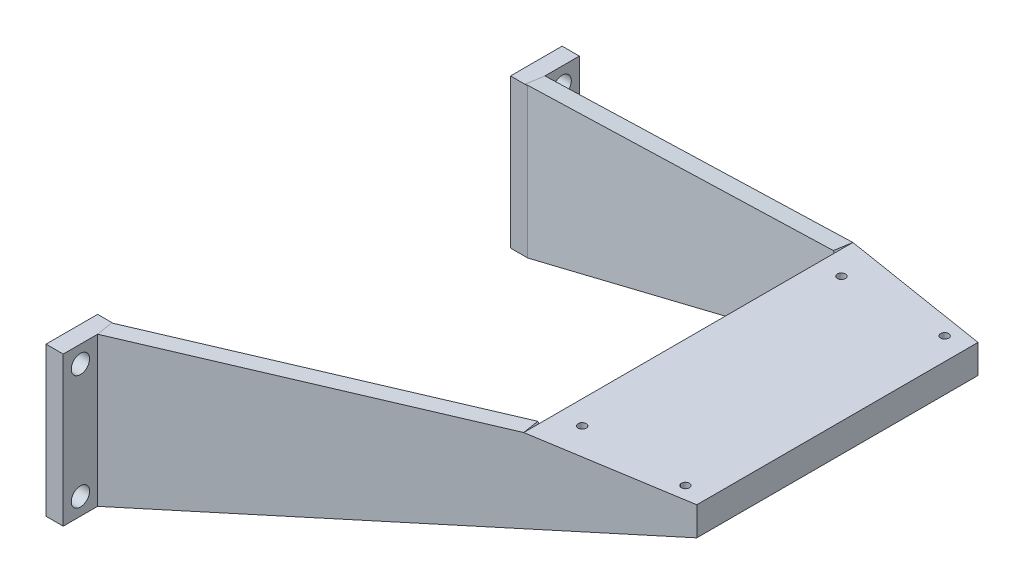
from build123d import *

# Parameters (mm, degrees)
SKETCH_1_W          = 6
SKETCH_1_H          = 26
SKETCH_1_R          = 1.6
EXTRUDE_1_DEPTH     = 3
EXTRUDE_1_2_DEPTH   = 3
SKETCH_11_W         = 3
SKETCH_11_H         = 10
SKETCH_10_W         = 3
SKETCH_10_H         = 26
SKETCH_13_W         = 3
SKETCH_13_H         = 10
SKETCH_12_W         = 3
SKETCH_12_H         = 26
SKETCH_14_W         = 50
SKETCH_14_H         = 10
EXTRUDE_4_DEPTH     = 3
SKETCH_15_W         = 19.024799208
SKETCH_15_H         = 22.305451654
CUT_EXTRUDE_2_DEPTH = 3
SKETCH_16_W         = 14.351226191
SKETCH_16_H         = 17.437681629
CUT_EXTRUDE_3_DEPTH = 3
SKETCH_17_W         = 3
SKETCH_17_H         = 26
EXTRUDE_5_DEPTH     = 3
EXTRUDE_6_DEPTH     = 3
EXTRUDE_10_DEPTH    = 2.961896
EXTRUDE_11_DEPTH    = 2.961896
CUT_EXTRUDE_4_DEPTH = 100
SKETCH_22_W         = 3
SKETCH_22_H         = 51.402298851
EXTRUDE_12_DEPTH    = 3
CUT_EXTRUDE_5_DEPTH = 3
SKETCH_24_R         = 0.7
CUT_EXTRUDE_6_DEPTH = 10


with BuildPart() as part:
    # 草图1 → 凸台-拉伸1 (new body)
    with BuildSketch(Plane(origin=(0, 0, 0), x_dir=(0, 0, -1), z_dir=(1, 0, 0))):
        with Locations((-2.817174515, -6.083780501)):
            Rectangle(SKETCH_1_W, SKETCH_1_H)
        with Locations((-2.817174515, -16.083780501)):
            Circle(SKETCH_1_R, mode=Mode.SUBTRACT)
        with Locations((-2.817174515, 3.916219499)):
            Circle(SKETCH_1_R, mode=Mode.SUBTRACT)
    extrude(amount=EXTRUDE_1_DEPTH)



with BuildPart() as body_2:
    # 草图1 → Extrude 1 2 (new body)
    with BuildSketch(Plane(origin=(0, 0, 0), x_dir=(0, 0, -1), z_dir=(1, 0, 0))):
        with Locations((-86.817174515, -6.083780501)):
            Rectangle(SKETCH_1_W, SKETCH_1_H)
        with Locations((-86.817174515, -16.083780501)):
            Circle(SKETCH_1_R, mode=Mode.SUBTRACT)
        with Locations((-86.817174515, 3.916219499)):
            Circle(SKETCH_1_R, mode=Mode.SUBTRACT)
    extrude(amount=EXTRUDE_1_2_DEPTH)


with BuildPart() as body_3:
    # 草图11 → 放样4 section 0
    with BuildSketch(Plane.ZY.offset(-90)):
        with Locations((21.317174515, 13.916219499)):
            Rectangle(SKETCH_11_W, SKETCH_11_H)
    # 草图10 → 放样4 section 1
    with BuildSketch(Plane(origin=(3, 0, 0), x_dir=(0, 0, -1), z_dir=(1, 0, 0))):
        with Locations((-7.317174515, -6.083780501)):
            Rectangle(SKETCH_10_W, SKETCH_10_H)
    loft()



with BuildPart() as body_4:
    # 草图13 → 放样5 section 0
    with BuildSketch(Plane.ZY.offset(-90)):
        with Locations((68.317174515, 13.916219499)):
            Rectangle(SKETCH_13_W, SKETCH_13_H)
    # 草图12 → 放样5 section 1
    with BuildSketch(Plane(origin=(3, 0, 0), x_dir=(0, 0, -1), z_dir=(1, 0, 0))):
        with Locations((-82.317174515, -6.083780501)):
            Rectangle(SKETCH_12_W, SKETCH_12_H)
    loft()


with BuildPart() as body_3_1:
    add(body_3.part)

    add(body_4.part)  # 凸台-拉伸4 merges body 4
    # 草图14 → 凸台-拉伸4 (add)
    with BuildSketch(Plane(origin=(90, 0, 0), x_dir=(0, 0, -1), z_dir=(1, 0, 0))):
        with Locations((-44.817174515, 13.916219499)):
            Rectangle(SKETCH_14_W, SKETCH_14_H)
    extrude(amount=EXTRUDE_4_DEPTH)

    # 草图15 → 切除-拉伸2 (cut)
    with BuildSketch(Plane(origin=(13.223093182, 0, 82.172079061), x_dir=(0.987298603, 0, -0.158875637), z_dir=(0.158875637, 0, 0.987298603))):
        with Locations((78.439469875, 13.430311671)):
            Rectangle(SKETCH_15_W, SKETCH_15_H)
    extrude(amount=CUT_EXTRUDE_2_DEPTH, mode=Mode.SUBTRACT)

    # 草图16 → 切除-拉伸3 (cut)
    with BuildSketch(Plane(origin=(-0.83674418, 0, 5.199767406), x_dir=(-0.987298603, 0, -0.158875637), z_dir=(0.158875637, 0, -0.987298603))):
        with Locations((-93.553254701, 14.072952005)):
            Rectangle(SKETCH_16_W, SKETCH_16_H)
    extrude(amount=CUT_EXTRUDE_3_DEPTH, mode=Mode.SUBTRACT)


with BuildPart() as part_1:
    add(part.part)

    add(body_2.part)  # 凸台-拉伸5 merges body 2

    add(body_3_1.part)  # 凸台-拉伸5 merges body 3
    # 草图17 → 凸台-拉伸5 (add)
    with BuildSketch(Plane.ZY.offset(-3)):
        with Locations((7.317174515, -6.083780501)):
            Rectangle(SKETCH_17_W, SKETCH_17_H)
        with Locations((82.317174515, -6.083780501)):
            Rectangle(SKETCH_17_W, SKETCH_17_H)
    extrude(amount=EXTRUDE_5_DEPTH)

    # 草图18 → 凸台-拉伸6 (add)
    with BuildSketch(Plane(origin=(0, 18.916219499, 0), x_dir=(1, 0, 0), z_dir=(0, 1, 0))):
        Polygon((93, -69.334415895), (67, -73.518323941), (67, -16.11602509), (93, -20.299933136), align=None)
    extrude(amount=-EXTRUDE_6_DEPTH)

    # 草图19 → 凸台-拉伸10 (add)
    with BuildSketch(Plane(origin=(13.223093182, 0, 82.172079061), x_dir=(0.987298603, 0, -0.158875637), z_dir=(0.158875637, 0, 0.987298603))):
        Polygon((-10.354611208, 6.916219499), (54.468735845, 18.916219499), (57.643062592, 15.200587801), (10.872988387, 4.084352126), align=None)
    extrude(amount=-EXTRUDE_10_DEPTH)

    # 草图20 → 凸台-拉伸11 (add)
    with BuildSketch(Plane(origin=(-0.83674418, 0, 5.199767406), x_dir=(-0.987298603, 0, -0.158875637), z_dir=(0.158875637, 0, -0.987298603))):
        Polygon((-3.886103118, 6.916219499), (-68.709450171, 18.916219499), (-71.52946793, 14.93833866), (-30.165426117, 5.801086138), align=None)
    extrude(amount=-EXTRUDE_11_DEPTH)

    # 草图21 → 切除-拉伸4 (cut)
    with BuildSketch(Plane(origin=(0, 0, -0.182825485), x_dir=(-1, 0, 0), z_dir=(0, 0, -1))):
        Polygon((-3, -19.083780501), (-93, 13.916219499), (-93, 8.916219499), align=None)
    extrude(amount=-CUT_EXTRUDE_4_DEPTH, mode=Mode.SUBTRACT)

    # 草图22 → 凸台-拉伸12 (add)
    with BuildSketch(Plane.XZ.offset(-15.916219499)):
        with Locations((68.5, 44.817174515)):
            Rectangle(SKETCH_22_W, SKETCH_22_H)
    extrude(amount=EXTRUDE_12_DEPTH)

    # 草图23 → 切除-拉伸5 (cut)
    with BuildSketch(Plane(origin=(70, 0, 0), x_dir=(0, 0, -1), z_dir=(1, 0, 0))):
        with BuildLine():
            Line((-19.598783711, 12.916219499), (-70.03556532, 12.916219499))
            ThreePointArc((-70.03556532, 12.916219499), (-44.817174515, 15.916219499), (-19.598783711, 12.916219499))
        make_face()
    extrude(amount=-CUT_EXTRUDE_5_DEPTH, mode=Mode.SUBTRACT)

    # 草图24 → 切除-拉伸6 (cut)
    with BuildSketch(Plane(origin=(0, 18.916219499, 0), x_dir=(1, 0, 0), z_dir=(0, 1, 0))):
        with Locations((89.1, -67.417174515)):
            Circle(SKETCH_24_R)
        with Locations((71.1, -67.417174515)):
            Circle(SKETCH_24_R)
        with Locations((71.1, -22.217174515)):
            Circle(SKETCH_24_R)
        with Locations((89.1, -22.217174515)):
            Circle(SKETCH_24_R)
    extrude(amount=-CUT_EXTRUDE_6_DEPTH, mode=Mode.SUBTRACT)


solid = part_1.part
